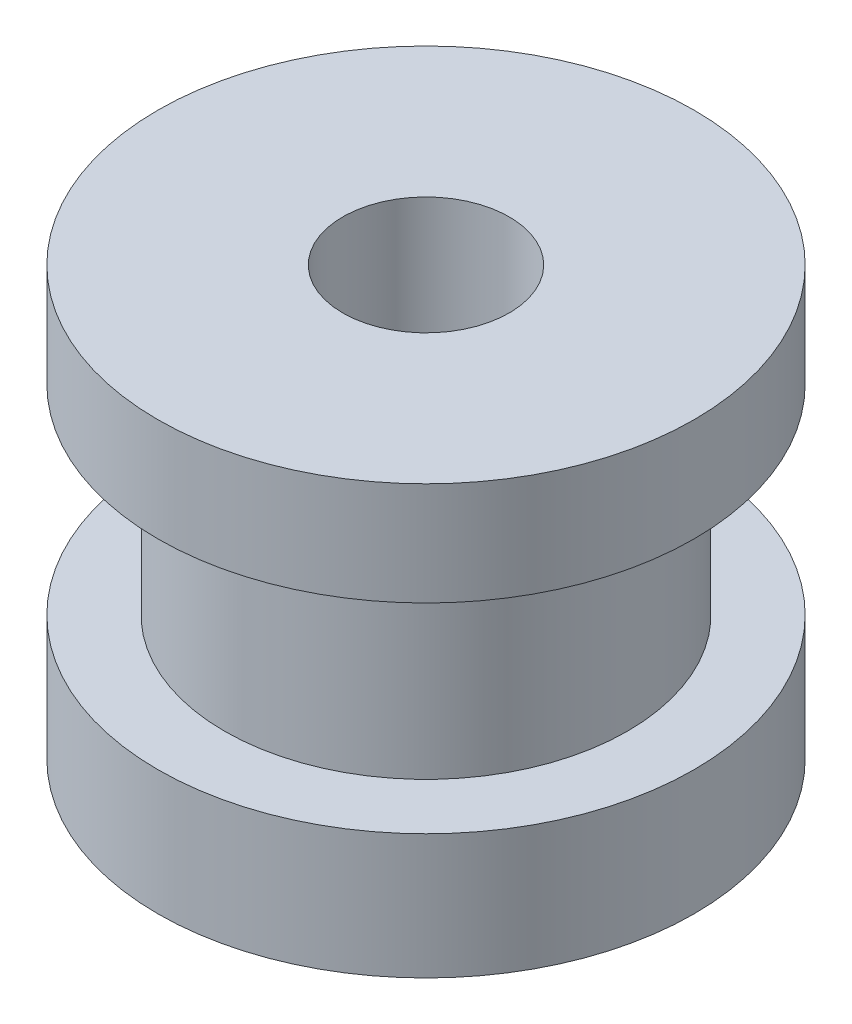
from build123d import *

# Parameters (mm, degrees)
SKETCH1_R           = 8.05
BOSS_EXTRUDE1_DEPTH = 3.75
SKETCH2_R           = 6.05
BOSS_EXTRUDE2_DEPTH = 6
SKETCH3_R           = 8.05
BOSS_EXTRUDE3_DEPTH = 3.1
SKETCH4_R           = 2.1
CUT_EXTRUDE1_DEPTH  = 6
SKETCH5_R           = 2.5
CUT_EXTRUDE2_DEPTH  = 7


with BuildPart() as part:
    # Sketch1 → Boss-Extrude1 (new body)
    with BuildSketch(Plane(origin=(0, 0, 0), x_dir=(1, 0, 0), z_dir=(0, 1, 0))):
        Circle(SKETCH1_R)
    extrude(amount=BOSS_EXTRUDE1_DEPTH)

    # Sketch2 → Boss-Extrude2 (add)
    with BuildSketch(Plane(origin=(0, 3.75, 0), x_dir=(1, 0, 0), z_dir=(0, 1, 0))):
        Circle(SKETCH2_R)
    extrude(amount=BOSS_EXTRUDE2_DEPTH)

    # Sketch3 → Boss-Extrude3 (add)
    with BuildSketch(Plane(origin=(0, 9.75, 0), x_dir=(1, 0, 0), z_dir=(0, 1, 0))):
        Circle(SKETCH3_R)
    extrude(amount=BOSS_EXTRUDE3_DEPTH)

    # Sketch4 → Cut-Extrude1 (cut)
    with BuildSketch(Plane.XZ):
        Circle(SKETCH4_R)
    extrude(amount=-CUT_EXTRUDE1_DEPTH, mode=Mode.SUBTRACT)

    # Sketch5 → Cut-Extrude2 (cut)
    with BuildSketch(Plane(origin=(0, 12.85, 0), x_dir=(1, 0, 0), z_dir=(0, 1, 0))):
        Circle(SKETCH5_R)
    extrude(amount=-CUT_EXTRUDE2_DEPTH, mode=Mode.SUBTRACT)


solid = part.part
